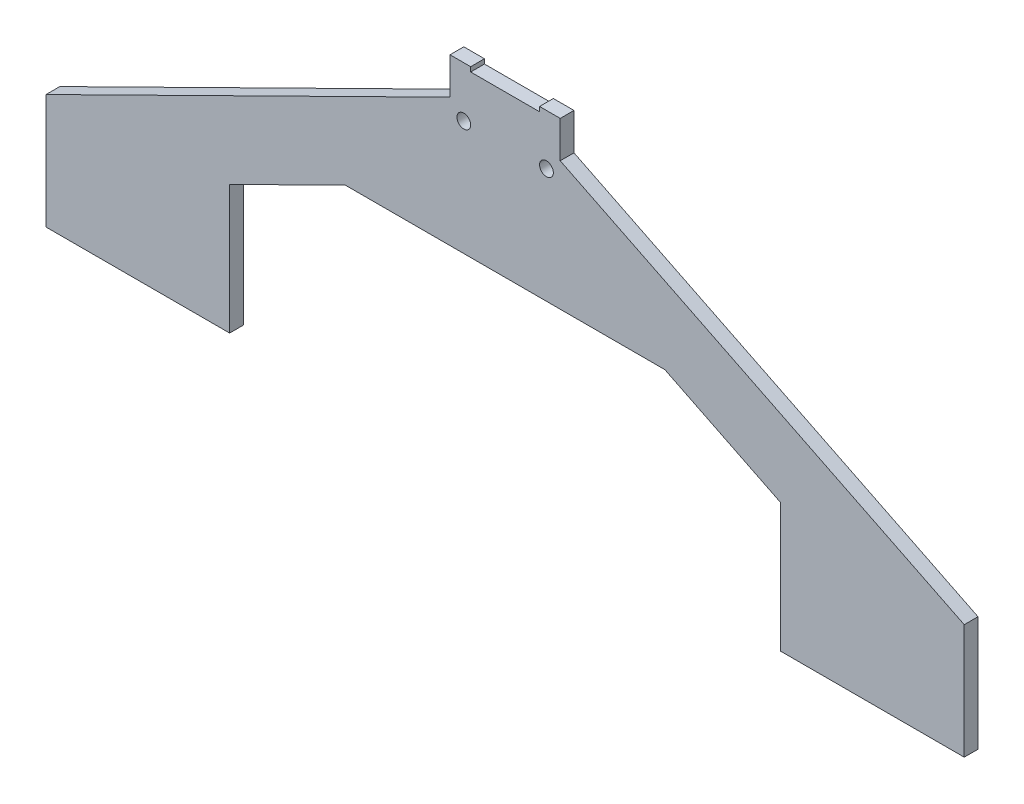
from build123d import *

# Parameters (mm, degrees)
EXTRUDE_1_DEPTH     = 3
SKETCH_3_R          = 1.5
CUT_EXTRUDE_1_DEPTH = 3


with BuildPart() as part:
    # 草图2 → 凸台-拉伸1 (new body)
    with BuildSketch(Plane(origin=(356.17996861, -2895.528235046, -3033.98121825), x_dir=(1, 0, 0), z_dir=(0, 0, 1))):
        Polygon((-296.17996861, 2848.06839364), (-321.386084558, 2860.528235046), (-390.973852662, 2860.528235046), (-416.17996861, 2848.06839364), (-416.17996861, 2820.028235046), (-456.17996861, 2820.028235046), (-456.17996861, 2845.028235046), (-368.17996861, 2888.528235046), (-368.17996861, 2896.528235046), (-363.67996861, 2896.528235046), (-363.67996861, 2895.528235046), (-348.67996861, 2895.528235046), (-348.67996861, 2896.528235046), (-344.17996861, 2896.528235046), (-344.17996861, 2888.528235046), (-256.17996861, 2845.028235046), (-256.17996861, 2820.028235046), (-296.17996861, 2820.028235046), align=None)
    extrude(amount=EXTRUDE_1_DEPTH)

    # 草图3 → 切除-拉伸1 (cut)
    with BuildSketch(Plane.XY.offset(-3030.98121825)):
        with Locations((9, -10)):
            Circle(SKETCH_3_R)
        with Locations((-9, -10)):
            Circle(SKETCH_3_R)
    extrude(amount=-CUT_EXTRUDE_1_DEPTH, mode=Mode.SUBTRACT)


solid = part.part
